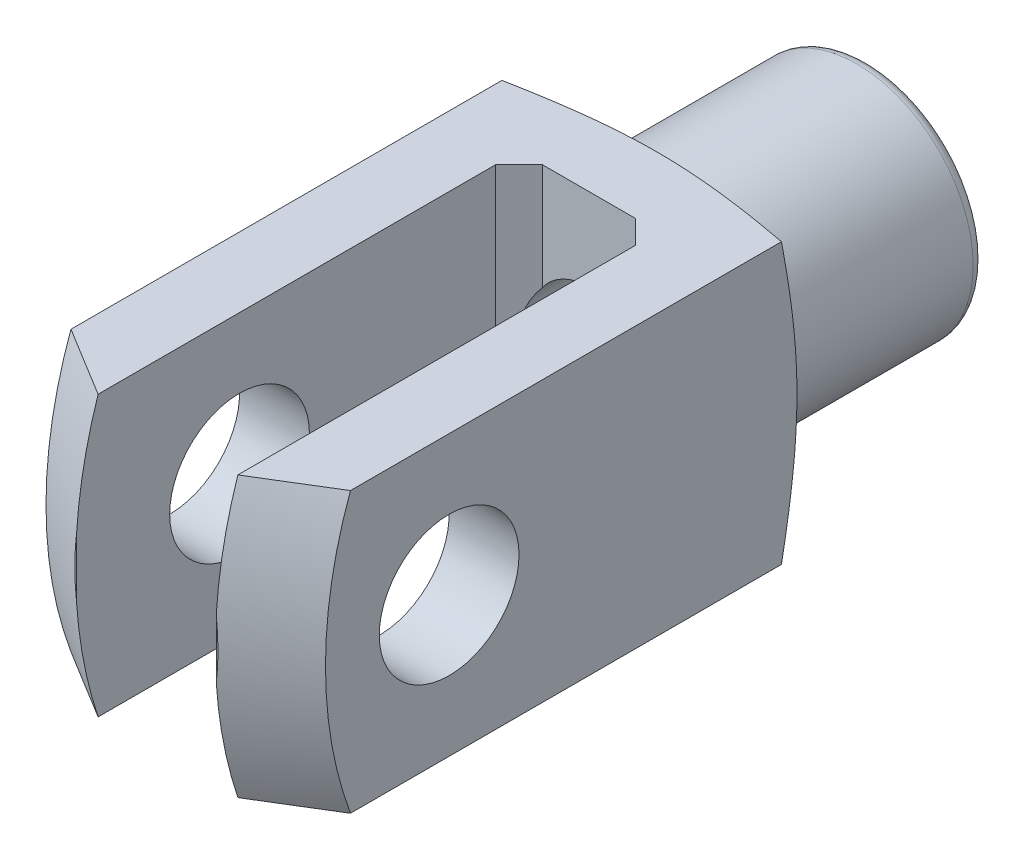
from build123d import *

# Parameters (mm, degrees)
CUT_EXTRUDE1_DEPTH           = 13
CUT_EXTRUDE1_DEPTH_BACK      = 13
CUT_EXTRUDE2_DEPTH           = 13
CUT_EXTRUDE2_DEPTH_BACK      = 13
CUT_EXTRUDE3_DEPTH           = 13
CUT_EXTRUDE3_DEPTH_BACK      = 13
SKETCH5_W                    = 16.2
SKETCH5_H                    = 3
CUT_REVOLVE3_ANGLE           = 90
CUT_REVOLVE3_OTHER_WAY_ANGLE = 90


with BuildPart() as part:
    # Sketch1 → Revolve1 (revolve)
    with BuildSketch(Plane(origin=(0, 0, 0), x_dir=(0, 0, -1), z_dir=(1, 0, 0))):
        with BuildLine():
            Line((-7, 0), (-7, 12))
            Line((-7, 12), (13.325317547, 12))
            Line((13.325317547, 12), (15, 5.75))
            ThreePointArc((15, 5.75), (15.219669914, 5.219669914), (15.75, 5))
            Line((15.75, 5), (23.5, 5))
            ThreePointArc((23.5, 5), (23.853553391, 4.853553391), (24, 4.5))
            Line((24, 4.5), (24, 0))
            Line((24, 0), (-7, 0))
        make_face()
    revolve(axis=Axis((0, 0, -24), (0, 0, 1)))

    # Sketch2 → Cut-Extrude1 (cut, two sides: drawn at the far end of the back side and taken through both)
    with BuildSketch(Plane(origin=(0, 0, 0), x_dir=(1, 0, 0), z_dir=(0, 1, 0)).offset(-CUT_EXTRUDE1_DEPTH_BACK)):
        Polygon((-3, 11), (-3, -8), (3, -8), (3, 11), (2, 12), (-2, 12), align=None)
    extrude(amount=CUT_EXTRUDE1_DEPTH + CUT_EXTRUDE1_DEPTH_BACK, mode=Mode.SUBTRACT)

    # Sketch3 → Cut-Extrude2 (cut, two sides: drawn at the far end of the back side and taken through both)
    with BuildSketch(Plane(origin=(0, 0, 0), x_dir=(0, 0, -1), z_dir=(1, 0, 0)).offset(-CUT_EXTRUDE2_DEPTH_BACK)):
        Polygon((-20, -18), (24, -18), (24, -6), (-8, -6), (-8, 6), (24, 6), (24, 18), (-20, 18), align=None)
    extrude(amount=CUT_EXTRUDE2_DEPTH + CUT_EXTRUDE2_DEPTH_BACK, mode=Mode.SUBTRACT)

    # Sketch4 → Cut-Extrude3 (cut, two sides: drawn at the far end of the back side and taken through both)
    with BuildSketch(Plane(origin=(0, 0, 0), x_dir=(1, 0, 0), z_dir=(0, 1, 0)).offset(-CUT_EXTRUDE3_DEPTH_BACK)):
        Polygon((-18, -20), (18, -20), (18, 24), (6, 24), (6, -8), (-6, -8), (-6, 24), (-18, 24), align=None)
    extrude(amount=CUT_EXTRUDE3_DEPTH + CUT_EXTRUDE3_DEPTH_BACK, mode=Mode.SUBTRACT)

    # Sketch5 → Cut-Revolve1 (revolve, cut)
    with BuildSketch(Plane.XY):
        with Locations((0, 1.5)):
            Rectangle(SKETCH5_W, SKETCH5_H)
    revolve(axis=Axis((8.1, 0, 0), (-1, 0, 0)), mode=Mode.SUBTRACT)

    # Sketch6 → Cut-Revolve2 (revolve, cut)
    with BuildSketch(Plane(origin=(0, 0, 0), x_dir=(0, 0, -1), z_dir=(1, 0, 0))):
        Polygon((10.9, 0), (10.9, 2.4585), (23.5585, 2.4585), (24.1, 3), (24.1, 0), align=None)
    revolve(axis=Axis((0, 0, -24.1), (0, 0, 1)), mode=Mode.SUBTRACT)

    # Sketch7 → Cut-Revolve3 (revolve, cut)
    with BuildSketch(Plane(origin=(0, 0, 0), x_dir=(1, 0, 0), z_dir=(0, 1, 0))):
        Polygon((-7, -18.589270357), (0, -22.630722241), (7, -18.589270357), (7, -4.732863896), (0, -8.774315781), (-7, -4.732863896), align=None)
    revolve(axis=Axis((-7, 0, -12), (-1, 0, 0)), revolution_arc=CUT_REVOLVE3_ANGLE, mode=Mode.SUBTRACT)

    # Sketch7 → Cut-Revolve3 other way (revolve, cut)
    with BuildSketch(Plane(origin=(0, 0, 0), x_dir=(1, 0, 0), z_dir=(0, 1, 0))):
        Polygon((-7, -18.589270357), (0, -22.630722241), (7, -18.589270357), (7, -4.732863896), (0, -8.774315781), (-7, -4.732863896), align=None)
    revolve(axis=Axis((-7, 0, -12), (1, 0, 0)), revolution_arc=CUT_REVOLVE3_OTHER_WAY_ANGLE, mode=Mode.SUBTRACT)


solid = part.part
